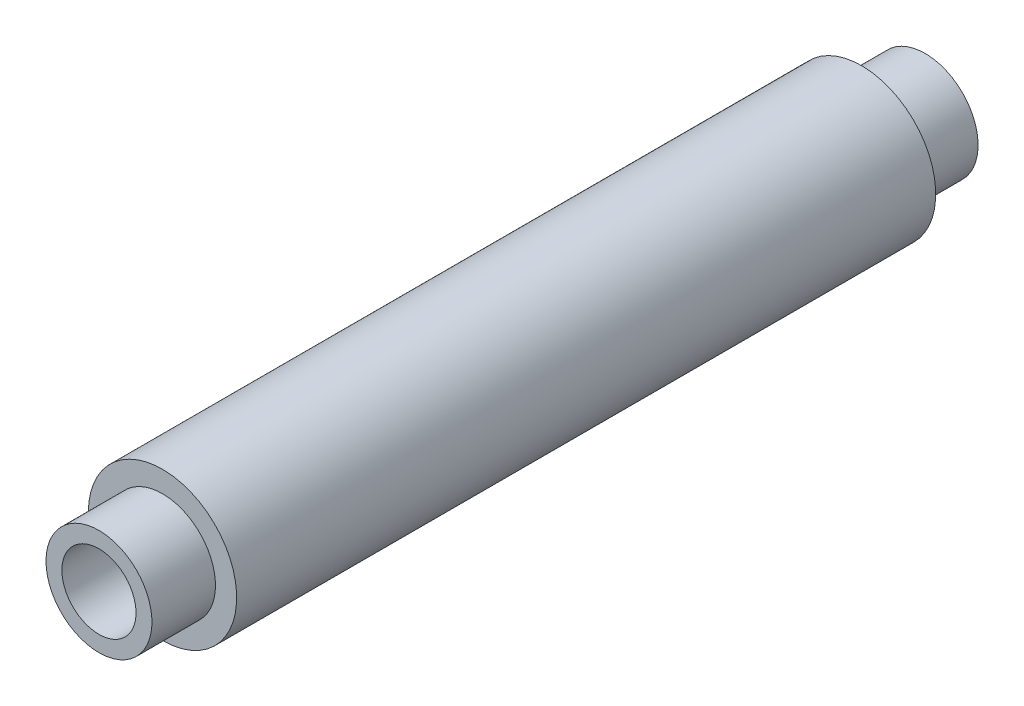
from build123d import *

# Parameters (mm, degrees)
SHELL1_T = -0.75


with BuildPart() as part:
    # Sketch1 → Revolve1 (revolve)
    with BuildSketch(Plane(origin=(0, 0, 0), x_dir=(1, 0, 0), z_dir=(0, 1, 0)), mode=Mode.PRIVATE) as revolve1_sk:
        Polygon((3.5, 16.5), (3.5, -16.5), (2.5, -16.5), (2.5, -19.5), (0, -19.5), (0, -16.5), (0, 16.5), (0, 19.5), (2.5, 19.5), (2.5, 16.5), align=None)
    revolve(revolve1_sk.sketch.rotate(Axis((0, 0, -21.376645948), (0, 0, 1)), 180), axis=Axis((0, 0, -21.376645948), (0, 0, 1)))

    # Shell1
    shell1_openings = [part.faces().sort_by_distance(p)[0] for p in [
        (0, 0, -19.5),
        (0, 0, 19.5),
    ]]
    offset(amount=SHELL1_T, openings=shell1_openings, kind=Kind.INTERSECTION)


solid = part.part
